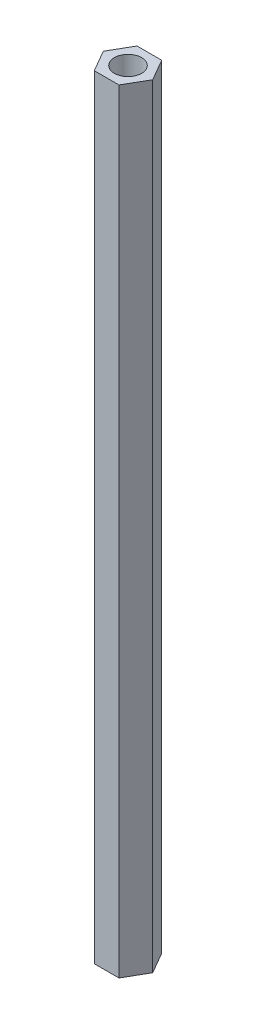
from build123d import *

# Parameters (mm, degrees)
SKETCH2_R           = 1.5
BOSS_EXTRUDE1_DEPTH = 85


with BuildPart() as part:
    # Sketch2 → Boss-Extrude1 (new body)
    with BuildSketch(Plane(origin=(0, 0, 0), x_dir=(1, 0, 0), z_dir=(0, 1, 0))):
        Polygon((2.713546265, 0), (1.356773133, 2.35), (-1.356773133, 2.35), (-2.713546265, 0), (-1.356773133, -2.35), (1.356773133, -2.35), align=None)
        Circle(SKETCH2_R, mode=Mode.SUBTRACT)
    extrude(amount=BOSS_EXTRUDE1_DEPTH)


solid = part.part
